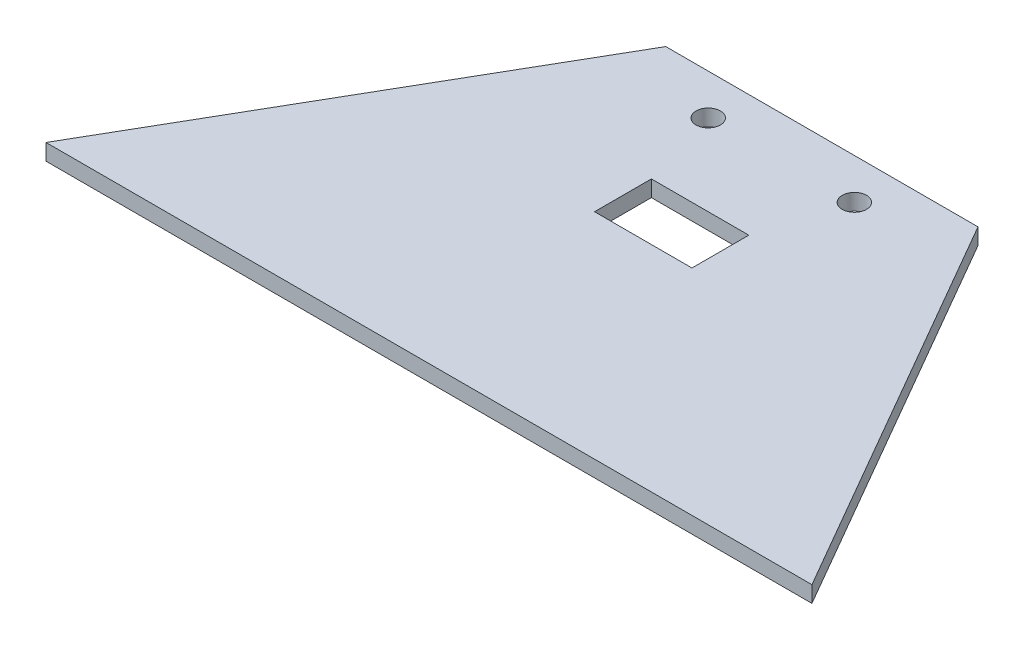
from build123d import *

# Parameters (mm, degrees)
ESQUISSE1_R        = 1.5
ESQUISSE1_W        = 12
ESQUISSE1_H        = 7
BOSS_EXTRU_1_DEPTH = 2


with BuildPart() as part:
    # Esquisse1 → Boss.-Extru.1 (new body)
    with BuildSketch(Plane(origin=(0, 0, 0), x_dir=(1, 0, 0), z_dir=(0, 1, 0))):
        Polygon((-18.31712618, 39.132721947), (20.135868436, 39.132721947), (48.074434638, -9.258294204), (-46.255692381, -9.258294204), align=None)
        with Locations((-8.090628872, 34.132721947)):
            Circle(ESQUISSE1_R, mode=Mode.SUBTRACT)
        with Locations((9.909371128, 34.132721947)):
            Circle(ESQUISSE1_R, mode=Mode.SUBTRACT)
        with Locations((0.909371128, 20.632721947)):
            Rectangle(ESQUISSE1_W, ESQUISSE1_H, mode=Mode.SUBTRACT)
    extrude(amount=BOSS_EXTRU_1_DEPTH)


solid = part.part
